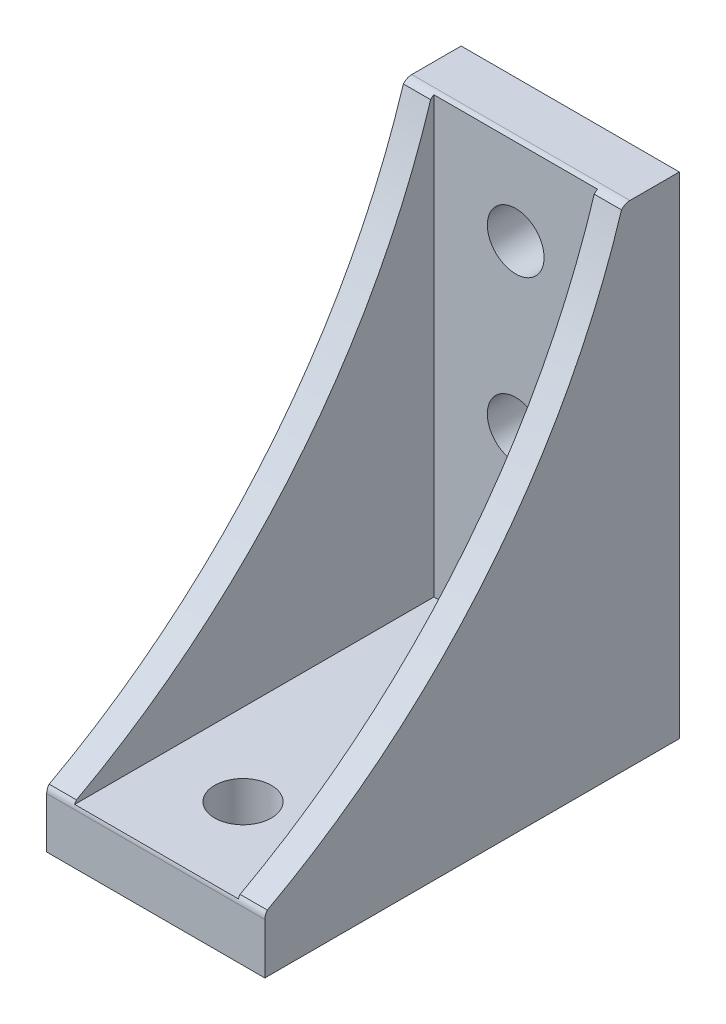
from build123d import *
from build123d.topology import SkipClean

# Parameters (mm, degrees)
BOSS_EXTRUDE1_DEPTH      = 10
BOSS_EXTRUDE1_DEPTH_BACK = 10
CUT_EXTRUDE1_DEPTH       = 7.5
CUT_EXTRUDE1_DEPTH_BACK  = 7.5
SKETCH2_W                = 38
SKETCH2_H                = 45
CUT_EXTRUDE2_DEPTH       = 10
CUT_EXTRUDE2_DEPTH_BACK  = 10
SKETCH4_R                = 2.6
CUT_EXTRUDE3_DEPTH       = 5
SKETCH5_R                = 2.6
CUT_EXTRUDE4_DEPTH       = 5
SKETCH6_R                = 2.6
CUT_EXTRUDE5_DEPTH       = 5
SKETCH7_R                = 2.6
CUT_EXTRUDE6_DEPTH       = 5
SKETCH8_W                = 20
SKETCH8_H                = 38
BOSS_EXTRUDE2_DEPTH      = 0.8
SKETCH9_W                = 20
SKETCH9_H                = 45
BOSS_EXTRUDE3_DEPTH      = 0.8
CUT_EXTRUDE7_START       = -0.8
SKETCH10_W               = 20
SKETCH10_H               = 38
CUT_EXTRUDE7_DEPTH       = 0.8
SKETCH11_W               = 20
SKETCH11_H               = 45
CUT_EXTRUDE8_DEPTH       = 1.25


with BuildPart() as part:
    # Sketch1 → Boss-Extrude1 (new, two sides: drawn at the far end of the back side and taken through both)
    with BuildSketch(Plane(origin=(0, 0, 0), x_dir=(0, 0, -1), z_dir=(1, 0, 0)).offset(-BOSS_EXTRUDE1_DEPTH_BACK)):
        with BuildLine():
            Line((-38, 0), (0, 0))
            Line((0, 0), (0, 45))
            Line((0, 45), (-4.528610784, 45))
            ThreePointArc((-4.528610784, 45), (-4.95500089, 44.904539373), (-5.299984062, 44.636382955))
            Line((-5.299984062, 44.636382955), (-37.771373279, 5.277123299))
            ThreePointArc((-37.771373279, 5.277123299), (-37.94110926, 4.978842933), (-38, 4.640740344))
            Line((-38, 4.640740344), (-38, 0))
        make_face()
    extrude(amount=BOSS_EXTRUDE1_DEPTH + BOSS_EXTRUDE1_DEPTH_BACK)

    # Sketch2 → Cut-Extrude1 (cut, two sides: drawn at the far end of the back side and taken through both)
    with BuildSketch(Plane(origin=(0, 0, 0), x_dir=(0, 0, -1), z_dir=(1, 0, 0)).offset(-CUT_EXTRUDE1_DEPTH_BACK)):
        with Locations((-24, 27.5)):
            Rectangle(SKETCH2_W, SKETCH2_H)
    extrude(amount=CUT_EXTRUDE1_DEPTH + CUT_EXTRUDE1_DEPTH_BACK, mode=Mode.SUBTRACT)

    # Sketch3 → Cut-Extrude2 (cut, two sides: drawn at the far end of the back side and taken through both)
    with BuildSketch(Plane(origin=(0, 0, 0), x_dir=(0, 0, -1), z_dir=(1, 0, 0)).offset(-CUT_EXTRUDE2_DEPTH_BACK)):
        with BuildLine():
            Line((-5.299984062, 44.636382955), (-37.771373279, 5.277123299))
            ThreePointArc((-37.771373279, 5.277123299), (-17.678812278, 21.774838353), (-5.299984062, 44.636382955))
        make_face()
    extrude(amount=CUT_EXTRUDE2_DEPTH + CUT_EXTRUDE2_DEPTH_BACK, mode=Mode.SUBTRACT)

    # Sketch4 → Cut-Extrude3 (cut)
    with BuildSketch(Plane(origin=(0, 0, 0), x_dir=(1, 0, 0), z_dir=(0, 1, 0))):
        with Locations((0, -10)):
            Circle(SKETCH4_R)
    extrude(amount=CUT_EXTRUDE3_DEPTH, mode=Mode.SUBTRACT)

    # Sketch5 → Cut-Extrude4 (cut)
    with BuildSketch(Plane(origin=(0, 0, 0), x_dir=(1, 0, 0), z_dir=(0, 1, 0))):
        with Locations((0, -30)):
            Circle(SKETCH5_R)
    extrude(amount=CUT_EXTRUDE4_DEPTH, mode=Mode.SUBTRACT)

    # Sketch6 → Cut-Extrude5 (cut)
    with BuildSketch(Plane.XY):
        with Locations((0, 22)):
            Circle(SKETCH6_R)
    extrude(amount=CUT_EXTRUDE5_DEPTH, mode=Mode.SUBTRACT)

    # Sketch7 → Cut-Extrude6 (cut)
    with BuildSketch(Plane.XY):
        with Locations((0, 37)):
            Circle(SKETCH7_R)
    extrude(amount=CUT_EXTRUDE6_DEPTH, mode=Mode.SUBTRACT)

    # Sketch8 → Boss-Extrude2 (add)
    with BuildSketch(Plane(origin=(0, 0, 0), x_dir=(1, 0, 0), z_dir=(0, 1, 0))):
        with Locations((0, -19)):
            Rectangle(SKETCH8_W, SKETCH8_H)
    extrude(amount=-BOSS_EXTRUDE2_DEPTH)

    # Sketch9 → Boss-Extrude3 (add)
    with BuildSketch(Plane.XY):
        with Locations((0, 22.5)):
            Rectangle(SKETCH9_W, SKETCH9_H)
    extrude(amount=-BOSS_EXTRUDE3_DEPTH)

    # Sketch10 → Cut-Extrude7 (cut)
    with SkipClean():  # the faces are left unmerged after this step: merging them gives an invalid solid
        with BuildSketch(Plane(origin=(0, 0, 0), x_dir=(1, 0, 0), z_dir=(0, 1, 0)).offset(CUT_EXTRUDE7_START)):
            with Locations((0, -19)):
                Rectangle(SKETCH10_W, SKETCH10_H)
            with BuildLine():
                Line((0.5, -33), (2, -33))
                ThreePointArc((2, -33), (2.707106781, -32.707106781), (3, -32))
                Line((3, -32), (3, -30.5))
                Line((3, -30.5), (2.551470164, -30.5))
                ThreePointArc((2.551470164, -30.5), (1.838477631, -31.838477631), (0.5, -32.551470164))
                Line((0.5, -32.551470164), (0.5, -33))
            make_face(mode=Mode.SUBTRACT)
            with BuildLine():
                Line((0.5, -27), (0.5, -27.448529836))
                ThreePointArc((0.5, -27.448529836), (1.838477631, -28.161522369), (2.551470164, -29.5))
                Line((2.551470164, -29.5), (3, -29.5))
                Line((3, -29.5), (3, -28))
                ThreePointArc((3, -28), (2.707106781, -27.292893219), (2, -27))
                Line((2, -27), (0.5, -27))
            make_face(mode=Mode.SUBTRACT)
            with BuildLine():
                Line((0.5, -13), (2, -13))
                ThreePointArc((2, -13), (2.707106781, -12.707106781), (3, -12))
                Line((3, -12), (3, -10.5))
                Line((3, -10.5), (2.551470164, -10.5))
                ThreePointArc((2.551470164, -10.5), (1.838477631, -11.838477631), (0.5, -12.551470164))
                Line((0.5, -12.551470164), (0.5, -13))
            make_face(mode=Mode.SUBTRACT)
            with BuildLine():
                Line((0.5, -7), (0.5, -7.448529836))
                ThreePointArc((0.5, -7.448529836), (1.838477631, -8.161522369), (2.551470164, -9.5))
                Line((2.551470164, -9.5), (3, -9.5))
                Line((3, -9.5), (3, -8))
                ThreePointArc((3, -8), (2.707106781, -7.292893219), (2, -7))
                Line((2, -7), (0.5, -7))
            make_face(mode=Mode.SUBTRACT)
            with BuildLine():
                Line((-2, -33), (-0.5, -33))
                Line((-0.5, -33), (-0.5, -32.551470164))
                ThreePointArc((-0.5, -32.551470164), (-1.838477631, -31.838477631), (-2.551470164, -30.5))
                Line((-2.551470164, -30.5), (-3, -30.5))
                Line((-3, -30.5), (-3, -32))
                ThreePointArc((-3, -32), (-2.707106781, -32.707106781), (-2, -33))
            make_face(mode=Mode.SUBTRACT)
            with BuildLine():
                Line((-3, -29.5), (-2.551470164, -29.5))
                ThreePointArc((-2.551470164, -29.5), (-1.838477631, -28.161522369), (-0.5, -27.448529836))
                Line((-0.5, -27.448529836), (-0.5, -27))
                Line((-0.5, -27), (-2, -27))
                ThreePointArc((-2, -27), (-2.707106781, -27.292893219), (-3, -28))
                Line((-3, -28), (-3, -29.5))
            make_face(mode=Mode.SUBTRACT)
            with BuildLine():
                Line((-2, -13), (-0.5, -13))
                Line((-0.5, -13), (-0.5, -12.551470164))
                ThreePointArc((-0.5, -12.551470164), (-1.838477631, -11.838477631), (-2.551470164, -10.5))
                Line((-2.551470164, -10.5), (-3, -10.5))
                Line((-3, -10.5), (-3, -12))
                ThreePointArc((-3, -12), (-2.707106781, -12.707106781), (-2, -13))
            make_face(mode=Mode.SUBTRACT)
            with BuildLine():
                Line((-3, -9.5), (-2.551470164, -9.5))
                ThreePointArc((-2.551470164, -9.5), (-1.838477631, -8.161522369), (-0.5, -7.448529836))
                Line((-0.5, -7.448529836), (-0.5, -7))
                Line((-0.5, -7), (-2, -7))
                ThreePointArc((-2, -7), (-2.707106781, -7.292893219), (-3, -8))
                Line((-3, -8), (-3, -9.5))
            make_face(mode=Mode.SUBTRACT)
        extrude(amount=CUT_EXTRUDE7_DEPTH, mode=Mode.SUBTRACT)

    # Sketch11 → Cut-Extrude8 (cut)
    with SkipClean():  # the faces are left unmerged after this step: merging them gives an invalid solid
        with BuildSketch(Plane.XY):
            with Locations((0, 22.5)):
                Rectangle(SKETCH11_W, SKETCH11_H)
            with BuildLine():
                Line((-2.7, 27), (2.7, 27))
                ThreePointArc((2.7, 27), (2.912132034, 27.087867966), (3, 27.3))
                Line((3, 27.3), (3, 32.7))
                ThreePointArc((3, 32.7), (2.912132034, 32.912132034), (2.7, 33))
                Line((2.7, 33), (-2.7, 33))
                ThreePointArc((-2.7, 33), (-2.912132034, 32.912132034), (-3, 32.7))
                Line((-3, 32.7), (-3, 27.3))
                ThreePointArc((-3, 27.3), (-2.912132034, 27.087867966), (-2.7, 27))
            make_face(mode=Mode.SUBTRACT)
            with BuildLine():
                Line((-2.7, 3), (2.7, 3))
                ThreePointArc((2.7, 3), (2.912132034, 3.087867966), (3, 3.3))
                Line((3, 3.3), (3, 7.7))
                ThreePointArc((3, 7.7), (2.912132034, 7.912132034), (2.7, 8))
                Line((2.7, 8), (-2.7, 8))
                ThreePointArc((-2.7, 8), (-2.912132034, 7.912132034), (-3, 7.7))
                Line((-3, 7.7), (-3, 3.3))
                ThreePointArc((-3, 3.3), (-2.912132034, 3.087867966), (-2.7, 3))
            make_face(mode=Mode.SUBTRACT)
        extrude(amount=-CUT_EXTRUDE8_DEPTH, mode=Mode.SUBTRACT)


solid = part.part
